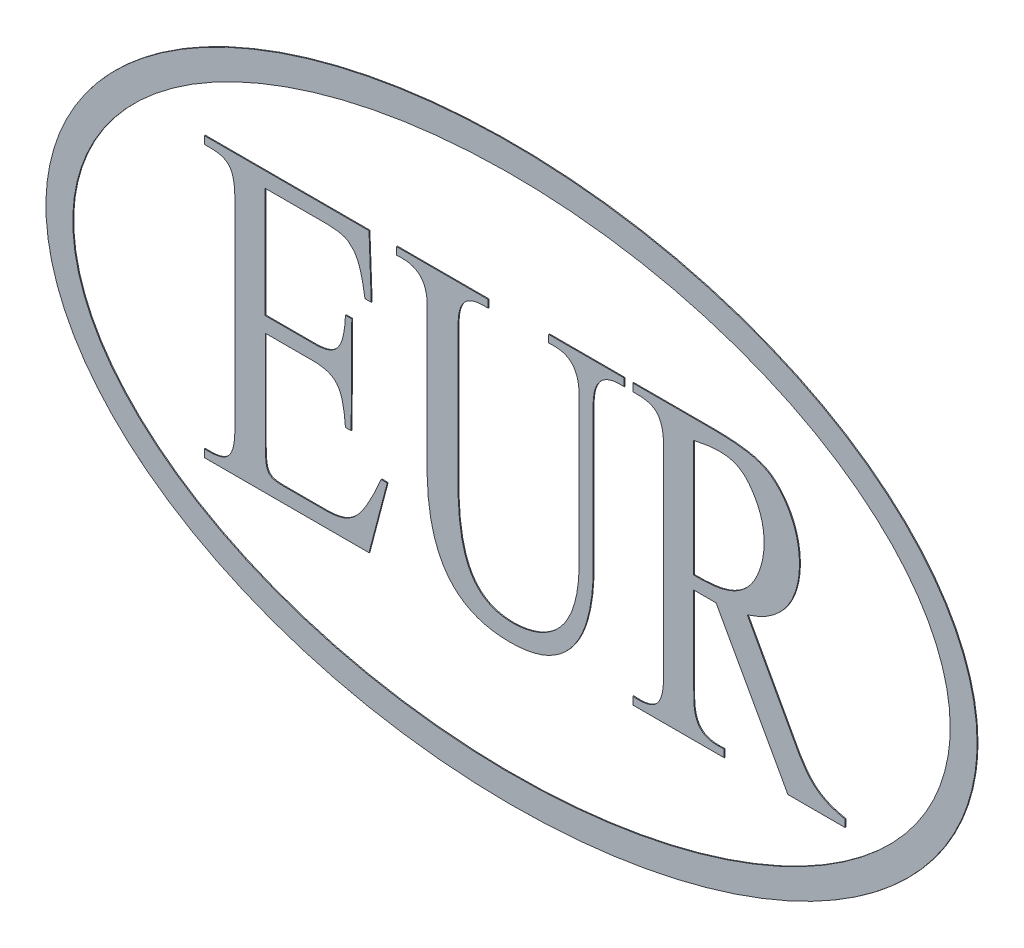
from build123d import *

# Parameters (mm, degrees)
BOSS_EXTRUDE1_DEPTH   = 0.1
BOSS_EXTRUDE1_2_DEPTH = 0.1
BOSS_EXTRUDE1_3_DEPTH = 0.1
BOSS_EXTRUDE1_4_DEPTH = 0.1


with BuildPart() as part:
    # Sketch2 → Boss-Extrude1 (new body)
    with BuildSketch(Plane.XY):
        with BuildLine():
            add(Edge.make_bspline(
                [(52, 0), (52, 2.228948685), (51.252049299, 6.686846055), (46.957076028, 15.014779342), (37.045073505, 23.70283763), (19.937399208, 30.438442012), (0, 32.780778994), (-19.937399208, 30.438442012), (-37.045073505, 23.70283763), (-46.957076028, 15.014779342), (-51.252049299, 6.686846055), (-52.373975351, 0), (-51.252049299, -6.686846055), (-46.957076028, -15.014779342), (-37.045073505, -23.70283763), (-19.937399208, -30.438442012), (0, -32.780778994), (19.937399208, -30.438442012), (37.045073505, -23.70283763), (46.957076028, -15.014779342), (51.252049299, -6.686846055), (52, -2.228948685), (52, 0)],
                knots=[0, 0, 0, 0, 0.196349541, 0.392699082, 0.785398163, 1.178097245, 1.570796327, 1.963495408, 2.35619449, 2.748893572, 2.945243113, 3.141592654, 3.337942194, 3.534291735, 3.926990817, 4.319689899, 4.71238898, 5.105088062, 5.497787144, 5.890486225, 6.086835766, 6.283185307, 6.283185307, 6.283185307, 6.283185307], degree=3))
        make_face()
        with BuildLine():
            add(Edge.make_bspline(
                [(49, 0), (49, 3.795670439), (46.448408259, 11.387011317), (35.55056883, 21.03970762), (19.239984052, 27.489984223), (0, 29.755007889), (-19.239984052, 27.489984223), (-35.55056883, 21.03970762), (-46.448408259, 11.387011317), (-50.27579587, 0), (-46.448408259, -11.387011317), (-35.55056883, -21.03970762), (-19.239984052, -27.489984223), (0, -29.755007889), (19.239984052, -27.489984223), (35.55056883, -21.03970762), (46.448408259, -11.387011317), (49, -3.795670439), (49, 0)],
                knots=[0, 0, 0, 0, 0.392699082, 0.785398163, 1.178097245, 1.570796327, 1.963495408, 2.35619449, 2.748893572, 3.141592654, 3.534291735, 3.926990817, 4.319689899, 4.71238898, 5.105088062, 5.497787144, 5.890486225, 6.283185307, 6.283185307, 6.283185307, 6.283185307], degree=3))
        make_face(mode=Mode.SUBTRACT)
    extrude(amount=BOSS_EXTRUDE1_DEPTH)


with BuildPart() as body_2:
    # Sketch2 → Boss-Extrude1 2 (new body)
    with BuildSketch(Plane.XY):
        with BuildLine():
            add(Edge.make_bspline(
                [(-20.53321378, -13.885218629), (-17.939312864, -13.772413756), (-16.799522635, -12.978542177), (-14.568659585, -7.790080027)],
                knots=[0, 0, 0, 0, 1, 1, 1, 1], degree=3))
            Line((-14.568659585, -7.790080027), (-13.877134811, -7.790080027))
            Line((-13.877134811, -7.790080027), (-15.914504346, -15.550846857))
            Line((-15.914504346, -15.550846857), (-34.293609895, -15.550846857))
            Line((-34.293609895, -15.550846857), (-34.293609895, -14.700144738))
            add(Edge.make_bspline(
                [(-34.293609895, -14.700144738), (-31.968772891, -14.779907863), (-30.906548608, -14.283541461), (-30.899759694, -11.099092097)],
                knots=[0, 0, 0, 0, 1, 1, 1, 1], degree=3))
            Line((-30.899759694, -11.099092097), (-30.899759694, 11.325023789))
            add(Edge.make_bspline(
                [(-34.293609895, 14.747236284), (-31.778109599, 14.818211839), (-30.947876885, 14.3734562), (-30.899759694, 11.325023789)],
                knots=[0, 0, 0, 0, 1, 1, 1, 1], degree=3))
            Line((-34.293609895, 14.747236284), (-34.293609895, 15.597938403))
            Line((-34.293609895, 15.597938403), (-15.914504346, 15.597938403))
            Line((-15.914504346, 15.597938403), (-15.662033514, 8.795657411))
            Line((-15.662033514, 8.795657411), (-16.36509046, 8.795657411))
            add(Edge.make_bspline(
                [(-20.53321378, 13.896534166), (-18.294312259, 13.839581008), (-18.157036428, 13.27588795), (-17.550235234, 12.812474393), (-16.97357798, 11.88327924), (-16.595935133, 10.240919383), (-16.36509046, 8.795657411)],
                knots=[0, 0, 0, 0, 0.3551707, 0.362824698, 0.712586444, 1, 1, 1, 1], degree=3))
            Line((-20.53321378, 13.896534166), (-27.54541593, 13.896534166))
            Line((-27.54541593, 13.896534166), (-27.54541593, 1.586206479))
            Line((-27.54541593, 1.586206479), (-21.846941027, 1.586206479))
            add(Edge.make_bspline(
                [(-21.846941027, 1.586206479), (-19.44999714, 1.652936266), (-18.703183708, 2.785128575), (-18.544290675, 6.102020656)],
                knots=[0, 0, 0, 0, 1, 1, 1, 1], degree=3))
            Line((-18.544290675, 6.102020656), (-17.841549223, 6.102020656))
            Line((-17.841549223, 6.102020656), (-17.909041715, -4.753876048))
            Line((-17.909041715, -4.753876048), (-18.544290675, -4.753876048))
            add(Edge.make_bspline(
                [(-21.846941027, -0.112348348), (-19.546458896, -0.279932578), (-18.831946887, -1.039390223), (-18.544290675, -4.753876048)],
                knots=[0, 0, 0, 0, 1, 1, 1, 1], degree=3))
            Line((-21.846941027, -0.112348348), (-27.498525868, -0.112348348))
            Line((-27.498525868, -0.112348348), (-27.498525868, -11.099092097))
            add(Edge.make_bspline(
                [(-27.498525868, -11.099092097), (-27.466279877, -13.44959927), (-27.298767976, -13.880675207), (-25.42275882, -13.885218629)],
                knots=[0, 0, 0, 0, 1, 1, 1, 1], degree=3))
            Line((-25.42275882, -13.885218629), (-20.53321378, -13.885218629))
        make_face()
    extrude(amount=BOSS_EXTRUDE1_2_DEPTH)


with BuildPart() as body_3:
    # Sketch2 → Boss-Extrude1 3 (new body)
    with BuildSketch(Plane.XY):
        with BuildLine():
            add(Edge.make_bspline(
                [(20.352093641, -10.729603141), (20.231039198, -13.902411712), (21.16673885, -14.9454865), (23.758399066, -14.700144738)],
                knots=[0, 0, 0, 0, 1, 1, 1, 1], degree=3))
            Line((23.758399066, -14.700144738), (23.758399066, -15.550846857))
            Line((23.758399066, -15.550846857), (13.543587323, -15.550846857))
            Line((13.543587323, -15.550846857), (13.543587323, -14.700144738))
            add(Edge.make_bspline(
                [(13.543587323, -14.700144738), (16.391102017, -14.964845803), (16.997492771, -13.659831466), (16.997492771, -10.729603141)],
                knots=[0, 0, 0, 0, 1, 1, 1, 1], degree=3))
            Line((16.997492771, -10.729603141), (16.997492771, 11.044513644))
            add(Edge.make_bspline(
                [(13.543587323, 14.747236284), (15.803445344, 14.809306146), (16.983104813, 14.396907936), (16.997492771, 11.044513644)],
                knots=[0, 0, 0, 0, 1, 1, 1, 1], degree=3))
            Line((13.543587323, 14.747236284), (13.543587323, 15.597938403))
            Line((13.543587323, 15.597938403), (22.641134615, 15.597938403))
            add(Edge.make_bspline(
                [(26.332206115, -0.436323387), (30.789152241, 0.921984004), (33.24235611, 6.986707397), (31.140211863, 12.511407914), (27.8220809, 15.364194811), (25.095698568, 15.558580899), (22.641134615, 15.597938403)],
                knots=[0, 0, 0, 0, 0.396590684, 0.711579889, 0.771920821, 1, 1, 1, 1], degree=3))
            Line((26.332206115, -0.436323387), (32.159715107, -11.099092097))
            add(Edge.make_bspline(
                [(32.159715107, -11.099092097), (33.449294015, -13.264862704), (34.567111916, -14.186934364), (37.259033439, -14.739075353)],
                knots=[0, 0, 0, 0, 1, 1, 1, 1], degree=3))
            Line((37.259033439, -14.739075353), (37.259033439, -15.550846857))
            Line((37.259033439, -15.550846857), (30.871625282, -15.550846857))
            Line((30.871625282, -15.550846857), (22.851624307, -1.023472219))
            Line((22.851624307, -1.023472219), (20.352093641, -1.023472219))
            Line((20.352093641, -1.023472219), (20.352093641, -10.729603141))
        make_face()
        with BuildLine():
            Line((20.352093641, 0.418392934), (20.352093641, 13.444875089))
            add(Edge.make_bspline(
                [(20.352093641, 13.444875089), (24.218881911, 14.346280196), (26.066009596, 13.426054743), (28.808218928, 8.459015126), (27.272463937, 0.709298708), (22.884174549, 0.398671861), (20.352093641, 0.418392934)],
                knots=[0, 0, 0, 0, 0.218696405, 0.277566845, 0.554133567, 1, 1, 1, 1], degree=3))
        make_face(mode=Mode.SUBTRACT)
    extrude(amount=BOSS_EXTRUDE1_3_DEPTH)


with BuildPart() as body_4:
    # Sketch2 → Boss-Extrude1 4 (new body)
    with BuildSketch(Plane.XY):
        with BuildLine():
            Line((-9.422695132, -4.753876048), (-9.422695132, 11.325023789))
            add(Edge.make_bspline(
                [(-12.849349073, 14.747236284), (-9.272289121, 15.136100425), (-9.422695132, 11.325023789)],
                knots=[0, 0, 0, 1, 1, 1], degree=2))
            Line((-12.849349073, 14.747236284), (-12.849349073, 15.597938403))
            Line((-12.849349073, 15.597938403), (-2.61249291, 15.597938403))
            Line((-2.61249291, 15.597938403), (-2.61249291, 14.747236284))
            add(Edge.make_bspline(
                [(-5.985207278, 11.325023789), (-5.956820836, 13.839995455), (-5.125196932, 14.880623058), (-2.61249291, 14.747236284)],
                knots=[0, 0, 0, 0, 1, 1, 1, 1], degree=3))
            Line((-5.985207278, 11.325023789), (-5.985207278, -4.753876048))
            add(Edge.make_bspline(
                [(-5.985207278, -4.753876048), (-5.805262357, -10.255375051), (-4.438289749, -14.102291276), (2.727023433, -14.505773424), (7.591207178, -12.177115011), (7.545192688, -4.753876048)],
                knots=[0, 0, 0, 0, 0.537407086, 0.637407086, 1, 1, 1, 1], degree=3))
            Line((7.545192688, -4.753876048), (7.545192688, 11.325023789))
            add(Edge.make_bspline(
                [(4.148730354, 14.747236284), (7.618425349, 15.136036682), (7.545192688, 11.325023789)],
                knots=[0, 0, 0, 1, 1, 1], degree=2))
            Line((4.148730354, 14.747236284), (4.148730354, 15.597938403))
            Line((4.148730354, 15.597938403), (12.586656857, 15.597938403))
            Line((12.586656857, 15.597938403), (12.586656857, 14.747236284))
            add(Edge.make_bspline(
                [(12.586656857, 14.747236284), (9.150668644, 15.00831748), (9.122057362, 11.325023789)],
                knots=[0, 0, 0, 1, 1, 1], degree=2))
            Line((9.122057362, 11.325023789), (9.122057362, -4.753876048))
            add(Edge.make_bspline(
                [(-9.422695132, -4.753876048), (-9.270011977, -12.325040179), (-5.833450526, -16.468864475), (6.438042765, -16.271024511), (9.044906788, -10.994541249), (9.122057362, -4.753876048)],
                knots=[0, 0, 0, 0, 0.431493336, 0.531493336, 1, 1, 1, 1], degree=3))
        make_face()
    extrude(amount=BOSS_EXTRUDE1_4_DEPTH)


solid = Compound([part.part, body_2.part, body_3.part, body_4.part])
